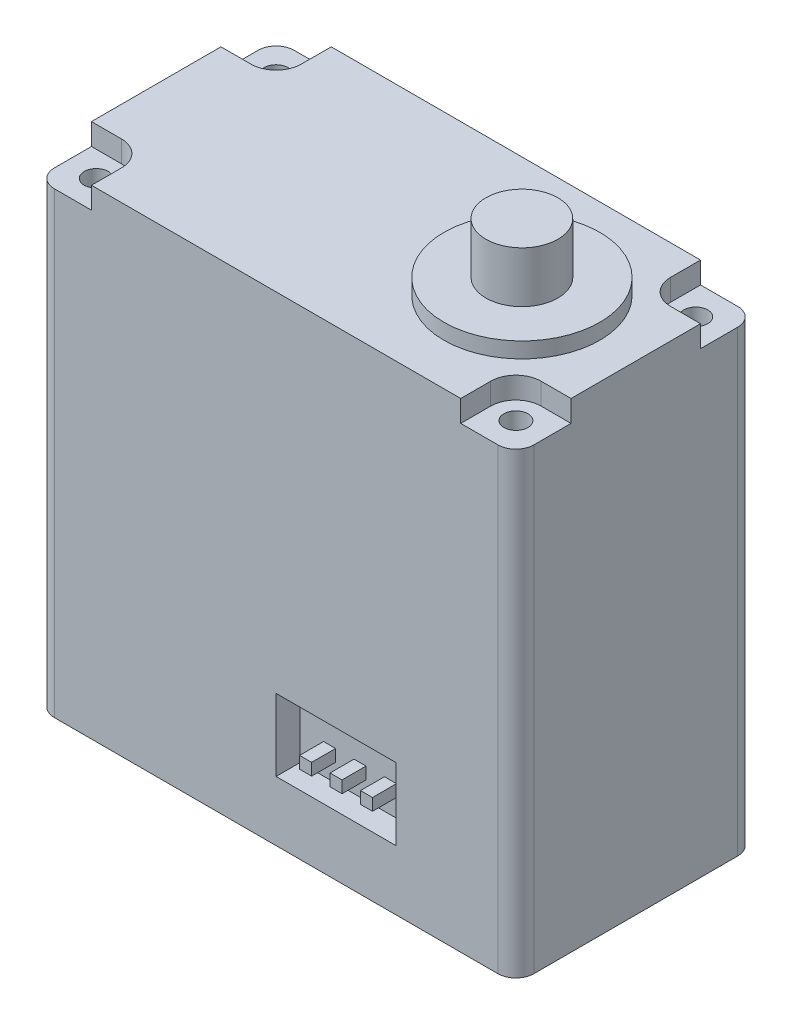
from build123d import *

# Parameters (mm, degrees)
SKETCH_1_W          = 40
SKETCH_1_H          = 20
EXTRUDE_1_DEPTH     = 20
FILLET_1_R          = 1.5
SKETCH_2_R          = 1
CUT_EXTRUDE_1_DEPTH = 41
SKETCH_3_R          = 2.1
SKETCH_3_R_2        = 1
CUT_EXTRUDE_2_DEPTH = 1.8
SKETCH_4_R          = 6.5
EXTRUDE_2_DEPTH     = 1.3
SKETCH_5_R          = 3
EXTRUDE_3_DEPTH     = 4.25
SKETCH_6_W          = 10
SKETCH_6_H          = 6
CUT_EXTRUDE_3_DEPTH = 2
SKETCH_7_W          = 1
SKETCH_7_H          = 1
EXTRUDE_4_DEPTH     = 2


with BuildPart() as part:
    # Эскиз1 → Бобышка-Вытянуть1 (new body, symmetric)
    with BuildSketch(Plane(origin=(0, 0, 0), x_dir=(1, 0, 0), z_dir=(0, 1, 0))):
        Rectangle(SKETCH_1_W, SKETCH_1_H)
    extrude(amount=EXTRUDE_1_DEPTH, both=True)

    # Скругление1
    fillet_1_edges = [part.edges().sort_by_distance(p)[0] for p in [
        (20, 0, 10),
        (-20, 0, 10),
        (-20, 0, -10),
        (20, 0, -10),
    ]]
    fillet(fillet_1_edges, radius=FILLET_1_R)

    # Эскиз2 → Вырез-Вытянуть1 (cut, through all)
    with BuildSketch(Plane(origin=(0, 20, 0), x_dir=(1, 0, 0), z_dir=(0, 1, 0))):
        with Locations((17.5, 7.5)):
            Circle(SKETCH_2_R)
        with Locations((17.5, -7.5)):
            Circle(SKETCH_2_R)
        with Locations((-17.5, -7.5)):
            Circle(SKETCH_2_R)
        with Locations((-17.5, 7.5)):
            Circle(SKETCH_2_R)
    extrude(amount=-CUT_EXTRUDE_1_DEPTH, mode=Mode.SUBTRACT)

    # Эскиз3 → Вырез-Вытянуть2 (cut)
    with BuildSketch(Plane(origin=(0, 20, 0), x_dir=(1, 0, 0), z_dir=(0, 1, 0))):
        with Locations((-17.5, 7.5)):
            Circle(SKETCH_3_R)
        with Locations((-17.5, 7.5)):
            Circle(SKETCH_3_R_2, mode=Mode.SUBTRACT)
        with BuildLine():
            Line((-20, 8.5), (-20, 5.4))
            Line((-20, 5.4), (-17.5, 5.4))
            ThreePointArc((-17.5, 5.4), (-18.98492424, 8.98492424), (-15.4, 7.5))
            Line((-15.4, 7.5), (-15.4, 10))
            Line((-15.4, 10), (-18.5, 10))
            ThreePointArc((-18.5, 10), (-19.560660172, 9.560660172), (-20, 8.5))
        make_face()
        with Locations((-17.5, -7.5)):
            Circle(SKETCH_3_R)
        with Locations((-17.5, -7.5)):
            Circle(SKETCH_3_R_2, mode=Mode.SUBTRACT)
        with BuildLine():
            Line((-17.5, -5.4), (-20, -5.4))
            Line((-20, -5.4), (-20, -8.5))
            ThreePointArc((-20, -8.5), (-19.560660172, -9.560660172), (-18.5, -10))
            Line((-18.5, -10), (-15.4, -10))
            Line((-15.4, -10), (-15.4, -7.5))
            ThreePointArc((-15.4, -7.5), (-18.98492424, -8.98492424), (-17.5, -5.4))
        make_face()
        with BuildLine():
            Line((15.4, -7.499999992), (15.4, -10))
            Line((15.4, -10), (18.5, -10))
            ThreePointArc((18.5, -10), (19.560660172, -9.560660172), (20, -8.5))
            Line((20, -8.5), (20, -5.4))
            Line((20, -5.4), (17.5, -5.4))
            ThreePointArc((17.5, -5.4), (18.98492424, -6.01507576), (19.6, -7.5))
            ThreePointArc((19.6, -7.5), (17.499999996, -9.6), (15.4, -7.499999992))
        make_face()
        with Locations((17.5, -7.5)):
            Circle(SKETCH_3_R)
        with Locations((17.5, -7.5)):
            Circle(SKETCH_3_R_2, mode=Mode.SUBTRACT)
        with BuildLine():
            Line((18.5, 10), (15.4, 10))
            Line((15.4, 10), (15.4, 7.500000012))
            ThreePointArc((15.4, 7.500000012), (17.500000006, 9.6), (19.6, 7.5))
            ThreePointArc((19.6, 7.5), (18.98492424, 6.01507576), (17.5, 5.4))
            Line((17.5, 5.4), (20, 5.4))
            Line((20, 5.4), (20, 8.5))
            ThreePointArc((20, 8.5), (19.560660172, 9.560660172), (18.5, 10))
        make_face()
        with Locations((17.5, 7.5)):
            Circle(SKETCH_3_R)
        with Locations((17.5, 7.5)):
            Circle(SKETCH_3_R_2, mode=Mode.SUBTRACT)
    extrude(amount=-CUT_EXTRUDE_2_DEPTH, mode=Mode.SUBTRACT)

    # Эскиз4 → Бобышка-Вытянуть2 (add)
    with BuildSketch(Plane(origin=(0, 20, 0), x_dir=(1, 0, 0), z_dir=(0, 1, 0))):
        with Locations((10.5, 0)):
            Circle(SKETCH_4_R)
    extrude_2 = extrude(amount=EXTRUDE_2_DEPTH)

    # Эскиз5 → Бобышка-Вытянуть3 (add)
    with BuildSketch(Plane(origin=(0, 21.3, 0), x_dir=(1, 0, 0), z_dir=(0, 1, 0))):
        with Locations((10.5, 0)):
            Circle(SKETCH_5_R)
    extrude_3 = extrude(amount=EXTRUDE_3_DEPTH)

    # Зеркальное отражение1: Бобышка-Вытянуть2, Бобышка-Вытянуть3 across plane
    add(extrude_2.mirror(Plane.ZX))
    add(extrude_3.mirror(Plane.ZX))

    # Эскиз6 → Вырез-Вытянуть3 (cut)
    with BuildSketch(Plane.XY.offset(10)):
        with Locations((5, -12)):
            Rectangle(SKETCH_6_W, SKETCH_6_H)
    extrude(amount=-CUT_EXTRUDE_3_DEPTH, mode=Mode.SUBTRACT)

    # Эскиз7 → Бобышка-Вытянуть4 (add)
    with BuildSketch(Plane.XY.offset(8)):
        with Locations((2.46, -13)):
            Rectangle(SKETCH_7_W, SKETCH_7_H)
        with Locations((5, -13)):
            Rectangle(SKETCH_7_W, SKETCH_7_H)
        with Locations((7.54, -13)):
            Rectangle(SKETCH_7_W, SKETCH_7_H)
    extrude(amount=EXTRUDE_4_DEPTH)


solid = part.part
